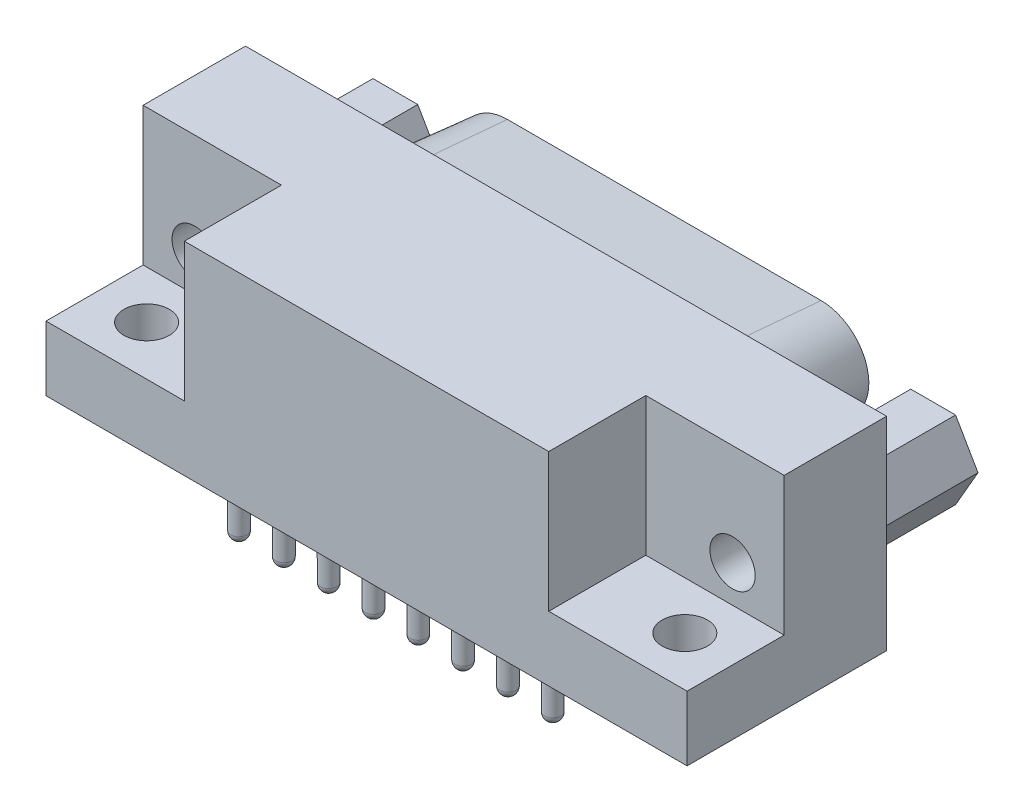
from build123d import *

# Parameters (mm, degrees)
SKETCH1_W                    = 39.62
SKETCH1_H                    = 12.33
BASE_EXTRUDE_DEPTH           = 12.55
SKETCH2_W                    = 8.55
SKETCH2_H                    = 6
CUT_EXTRUDE1_DEPTH           = 8.55
SKETCH3_R                    = 1.4
CUT_EXTRUDE2_DEPTH           = 33.442375067
BOSS_EXTRUDE1_DEPTH          = 6.07
SKETCH5_R                    = 1.4
CUT_EXTRUDE3_DEPTH           = 6.07
BOSS_EXTRUDE2_DEPTH          = 6.07
BOSS_EXTRUDE2_TAPER          = 5
SKETCH13_R                   = 1.4
CUT_EXTRUDE7_DEPTH           = 5
SKETCH7_R                    = 0.5
CUT_EXTRUDE4_DEPTH           = 9.47
CHAMFER1_SIZE                = 0.55
LPATTERN1_COUNT              = 8
LPATTERN1_PITCH              = 2.75
CHAMFER1_OF_LPATTERN1_SIZE   = 0.55
CUT_EXTRUDE5_START           = -9.47
SKETCH8_R                    = 0.5
CUT_EXTRUDE5_DEPTH           = 9.47
CHAMFER2_SIZE                = 0.55
LPATTERN2_COUNT              = 7
LPATTERN2_PITCH              = 2.75
CHAMFER2_OF_LPATTERN2_SIZE   = 0.55
SKETCH9_R                    = 0.5
BOSS_EXTRUDE3_DEPTH          = 3
DOME1_FACE_RADIUS            = 0.5
DOME1_HEIGHT                 = 0.5
LPATTERN3_COUNT              = 8
LPATTERN3_PITCH              = 2.77
LPATTERN3_COPY_1_FACE_RADIUS = 0.5
LPATTERN3_COPY_1_HEIGHT      = 0.5
LPATTERN3_COPY_2_FACE_RADIUS = 0.5
LPATTERN3_COPY_2_HEIGHT      = 0.5
LPATTERN3_COPY_3_FACE_RADIUS = 0.5
LPATTERN3_COPY_3_HEIGHT      = 0.5
LPATTERN3_COPY_4_FACE_RADIUS = 0.5
LPATTERN3_COPY_4_HEIGHT      = 0.5
LPATTERN3_COPY_5_FACE_RADIUS = 0.5
LPATTERN3_COPY_5_HEIGHT      = 0.5
LPATTERN3_COPY_6_FACE_RADIUS = 0.5
LPATTERN3_COPY_6_HEIGHT      = 0.5
LPATTERN3_COPY_7_FACE_RADIUS = 0.5
LPATTERN3_COPY_7_HEIGHT      = 0.5
SKETCH10_R                   = 0.5
BOSS_EXTRUDE4_DEPTH          = 3
DOME2_FACE_RADIUS            = 0.5
DOME2_HEIGHT                 = 0.5
LPATTERN4_COUNT              = 7
LPATTERN4_PITCH              = 2.77
LPATTERN4_COPY_1_FACE_RADIUS = 0.5
LPATTERN4_COPY_1_HEIGHT      = 0.5
LPATTERN4_COPY_2_FACE_RADIUS = 0.5
LPATTERN4_COPY_2_HEIGHT      = 0.5
LPATTERN4_COPY_3_FACE_RADIUS = 0.5
LPATTERN4_COPY_3_HEIGHT      = 0.5
LPATTERN4_COPY_4_FACE_RADIUS = 0.5
LPATTERN4_COPY_4_HEIGHT      = 0.5
LPATTERN4_COPY_5_FACE_RADIUS = 0.5
LPATTERN4_COPY_5_HEIGHT      = 0.5
LPATTERN4_COPY_6_FACE_RADIUS = 0.5
LPATTERN4_COPY_6_HEIGHT      = 0.5
CUT_EXTRUDE6_DEPTH           = 0.001


with BuildPart() as part:
    # Sketch1 → Base-Extrude (new body)
    with BuildSketch(Plane(origin=(0, 0, 0), x_dir=(1, 0, 0), z_dir=(0, 1, 0))):
        with Locations((9.65, 4.395)):
            Rectangle(SKETCH1_W, SKETCH1_H)
    extrude(amount=BASE_EXTRUDE_DEPTH)

    # Sketch2 → Cut-Extrude1 (cut)
    with BuildSketch(Plane(origin=(0, 12.55, 0), x_dir=(-1, 0, 0), z_dir=(0, 1, 0))):
        with Locations((5.885, -1.23)):
            Rectangle(SKETCH2_W, SKETCH2_H)
    cut_extrude1 = extrude(amount=-CUT_EXTRUDE1_DEPTH, mode=Mode.SUBTRACT)

    # Sketch3 → Cut-Extrude2 (cut, through all)
    with BuildSketch(Plane(origin=(0, 4, 0), x_dir=(-1, 0, 0), z_dir=(0, 1, 0))):
        with Locations(Location((6.98, -1.27, 0), (0, 0, 90))):
            Circle(SKETCH3_R)
    cut_extrude2 = extrude(amount=-CUT_EXTRUDE2_DEPTH, mode=Mode.SUBTRACT)

    # Sketch4 → Boss-Extrude1 (add)
    with BuildSketch(Plane(origin=(0, 0, -10.56), x_dir=(-1, 0, 0), z_dir=(0, 0, -1))):
        Polygon((8.355, 3.881109632), (5.585, 3.881109632), (4.2, 6.28), (5.585, 8.678890368), (8.355, 8.678890368), (9.74, 6.28), align=None)
    boss_extrude1 = extrude(amount=BOSS_EXTRUDE1_DEPTH)

    # Sketch5 → Cut-Extrude3 (cut)
    with BuildSketch(Plane(origin=(0, 0, -16.63), x_dir=(-1, 0, 0), z_dir=(0, 0, -1))):
        with Locations((6.97, 6.28)):
            Circle(SKETCH5_R)
    cut_extrude3 = extrude(amount=-CUT_EXTRUDE3_DEPTH, mode=Mode.SUBTRACT)

    # Sketch6 → Boss-Extrude2 (add)
    with BuildSketch(Plane(origin=(0, 0, -10.56), x_dir=(-1, 0, 0), z_dir=(0, 0, -1))):
        with BuildLine():
            ThreePointArc((-19.345, 11.18), (-22.388072176, 9.388227393), (-22.297527475, 5.857995247))
            Line((-22.297527475, 5.857995247), (-20.912527475, 3.637995247))
            ThreePointArc((-20.912527475, 3.637995247), (-19.648227393, 2.436927824), (-17.96, 2))
            Line((-17.96, 2), (-1.34, 2))
            ThreePointArc((-1.34, 2), (0.348227393, 2.436927824), (1.612527475, 3.637995247))
            Line((1.612527475, 3.637995247), (2.997527475, 5.857995247))
            ThreePointArc((2.997527475, 5.857995247), (3.088072176, 9.388227393), (0.045, 11.18))
            Line((0.045, 11.18), (-19.345, 11.18))
        make_face()
    extrude(amount=BOSS_EXTRUDE2_DEPTH, taper=BOSS_EXTRUDE2_TAPER)

    # Sketch13 → Cut-Extrude7 (cut)
    with BuildSketch(Plane.XY.offset(-4.23)):
        with Locations(Location((-6.97, 6.28, 0), (0, 0, 180))):
            Circle(SKETCH13_R)
    cut_extrude7 = extrude(amount=-CUT_EXTRUDE7_DEPTH, mode=Mode.SUBTRACT)

    # Mirror1: Cut-Extrude1, Cut-Extrude2, Boss-Extrude1, Cut-Extrude3, Cut-Extrude7 across plane
    add(cut_extrude1.mirror(Plane.ZY.offset(-9.65)), mode=Mode.SUBTRACT)
    add(cut_extrude2.mirror(Plane.ZY.offset(-9.65)), mode=Mode.SUBTRACT)
    add(boss_extrude1.mirror(Plane.ZY.offset(-9.65)))
    add(cut_extrude3.mirror(Plane.ZY.offset(-9.65)), mode=Mode.SUBTRACT)
    add(cut_extrude7.mirror(Plane.ZY.offset(-9.65)), mode=Mode.SUBTRACT)

    # Sketch7 → Cut-Extrude4 (cut)
    with BuildSketch(Plane(origin=(0, 0, -16.63), x_dir=(-1, 0, 0), z_dir=(0, 0, -1))):
        with Locations((-0.45, 7.69)):
            Circle(SKETCH7_R)
    cut_extrude4 = extrude(amount=-CUT_EXTRUDE4_DEPTH, mode=Mode.SUBTRACT)

    # Chamfer1
    chamfer1_edges = [part.edges().sort_by_distance(p)[0] for p in [
        (0.95, 7.69, -16.63),
    ]]
    chamfer(chamfer1_edges, length=CHAMFER1_SIZE)

    # LPattern1: Cut-Extrude4 ×8
    with Locations(*[(i * LPATTERN1_PITCH, 0, 0) for i in range(1, LPATTERN1_COUNT)]):
        add(cut_extrude4, mode=Mode.SUBTRACT)

    # Chamfer1 of LPattern1
    chamfer1_of_lpattern1_edges = [part.edges().sort_by_distance(p)[0] for p in [
        (3.7, 7.69, -16.63),
        (6.45, 7.69, -16.63),
        (9.2, 7.69, -16.63),
        (11.95, 7.69, -16.63),
        (14.7, 7.69, -16.63),
        (17.45, 7.69, -16.63),
        (20.2, 7.69, -16.63),
    ]]
    chamfer(chamfer1_of_lpattern1_edges, length=CHAMFER1_OF_LPATTERN1_SIZE)

    # Sketch8 → Cut-Extrude5 (cut)
    with BuildSketch(Plane(origin=(0, 0, -16.63), x_dir=(-1, 0, 0), z_dir=(0, 0, -1)).offset(CUT_EXTRUDE5_START)):
        with Locations((-1.825, 4.85)):
            Circle(SKETCH8_R)
    cut_extrude5 = extrude(amount=CUT_EXTRUDE5_DEPTH, mode=Mode.SUBTRACT)

    # Chamfer2
    chamfer2_edges = [part.edges().sort_by_distance(p)[0] for p in [
        (2.325, 4.85, -16.63),
    ]]
    chamfer(chamfer2_edges, length=CHAMFER2_SIZE)

    # LPattern2: Cut-Extrude5 ×7
    with Locations(*[(i * LPATTERN2_PITCH, 0, 0) for i in range(1, LPATTERN2_COUNT)]):
        add(cut_extrude5, mode=Mode.SUBTRACT)

    # Chamfer2 of LPattern2
    chamfer2_of_lpattern2_edges = [part.edges().sort_by_distance(p)[0] for p in [
        (5.075, 4.85, -16.63),
        (7.825, 4.85, -16.63),
        (10.575, 4.85, -16.63),
        (13.325, 4.85, -16.63),
        (16.075, 4.85, -16.63),
        (18.825, 4.85, -16.63),
    ]]
    chamfer(chamfer2_of_lpattern2_edges, length=CHAMFER2_OF_LPATTERN2_SIZE)

    # Sketch9 → Boss-Extrude3 (add)
    with BuildSketch(Plane.XZ):
        with Locations(Location((0, 0, 0), (0, 0, 90))):
            Circle(SKETCH9_R)
    boss_extrude3 = extrude(amount=BOSS_EXTRUDE3_DEPTH)

    # Dome1: a dome of height H over a round flat face of radius A is a cap of a sphere of radius (A * A + H * H) / (2 * H)
    dome1_r = (DOME1_FACE_RADIUS * DOME1_FACE_RADIUS + DOME1_HEIGHT * DOME1_HEIGHT) / (2 * DOME1_HEIGHT)
    dome1_base = Plane((0, -3, 0), z_dir=(0, -1, 0))
    with Locations(dome1_base.offset(DOME1_HEIGHT - dome1_r)):
        dome1_ball = Sphere(dome1_r, mode=Mode.PRIVATE)
    add(split(dome1_ball, bisect_by=dome1_base, keep=Keep.TOP, mode=Mode.PRIVATE))

    # LPattern3: Boss-Extrude3 ×8
    with Locations(*[(i * LPATTERN3_PITCH, 0, 0) for i in range(1, LPATTERN3_COUNT)]):
        add(boss_extrude3)

    # LPattern3 copy 1: a dome of height H over a round flat face of radius A is a cap of a sphere of radius (A * A + H * H) / (2 * H)
    lpattern3_copy_1_r = (LPATTERN3_COPY_1_FACE_RADIUS * LPATTERN3_COPY_1_FACE_RADIUS + LPATTERN3_COPY_1_HEIGHT * LPATTERN3_COPY_1_HEIGHT) / (2 * LPATTERN3_COPY_1_HEIGHT)
    lpattern3_copy_1_base = Plane((2.77, -3, 0), z_dir=(0, -1, 0))
    with Locations(lpattern3_copy_1_base.offset(LPATTERN3_COPY_1_HEIGHT - lpattern3_copy_1_r)):
        lpattern3_copy_1_ball = Sphere(lpattern3_copy_1_r, mode=Mode.PRIVATE)
    add(split(lpattern3_copy_1_ball, bisect_by=lpattern3_copy_1_base, keep=Keep.TOP, mode=Mode.PRIVATE))

    # LPattern3 copy 2: a dome of height H over a round flat face of radius A is a cap of a sphere of radius (A * A + H * H) / (2 * H)
    lpattern3_copy_2_r = (LPATTERN3_COPY_2_FACE_RADIUS * LPATTERN3_COPY_2_FACE_RADIUS + LPATTERN3_COPY_2_HEIGHT * LPATTERN3_COPY_2_HEIGHT) / (2 * LPATTERN3_COPY_2_HEIGHT)
    lpattern3_copy_2_base = Plane((5.54, -3, 0), z_dir=(0, -1, 0))
    with Locations(lpattern3_copy_2_base.offset(LPATTERN3_COPY_2_HEIGHT - lpattern3_copy_2_r)):
        lpattern3_copy_2_ball = Sphere(lpattern3_copy_2_r, mode=Mode.PRIVATE)
    add(split(lpattern3_copy_2_ball, bisect_by=lpattern3_copy_2_base, keep=Keep.TOP, mode=Mode.PRIVATE))

    # LPattern3 copy 3: a dome of height H over a round flat face of radius A is a cap of a sphere of radius (A * A + H * H) / (2 * H)
    lpattern3_copy_3_r = (LPATTERN3_COPY_3_FACE_RADIUS * LPATTERN3_COPY_3_FACE_RADIUS + LPATTERN3_COPY_3_HEIGHT * LPATTERN3_COPY_3_HEIGHT) / (2 * LPATTERN3_COPY_3_HEIGHT)
    lpattern3_copy_3_base = Plane((8.31, -3, 0), z_dir=(0, -1, 0))
    with Locations(lpattern3_copy_3_base.offset(LPATTERN3_COPY_3_HEIGHT - lpattern3_copy_3_r)):
        lpattern3_copy_3_ball = Sphere(lpattern3_copy_3_r, mode=Mode.PRIVATE)
    add(split(lpattern3_copy_3_ball, bisect_by=lpattern3_copy_3_base, keep=Keep.TOP, mode=Mode.PRIVATE))

    # LPattern3 copy 4: a dome of height H over a round flat face of radius A is a cap of a sphere of radius (A * A + H * H) / (2 * H)
    lpattern3_copy_4_r = (LPATTERN3_COPY_4_FACE_RADIUS * LPATTERN3_COPY_4_FACE_RADIUS + LPATTERN3_COPY_4_HEIGHT * LPATTERN3_COPY_4_HEIGHT) / (2 * LPATTERN3_COPY_4_HEIGHT)
    lpattern3_copy_4_base = Plane((11.08, -3, 0), z_dir=(0, -1, 0))
    with Locations(lpattern3_copy_4_base.offset(LPATTERN3_COPY_4_HEIGHT - lpattern3_copy_4_r)):
        lpattern3_copy_4_ball = Sphere(lpattern3_copy_4_r, mode=Mode.PRIVATE)
    add(split(lpattern3_copy_4_ball, bisect_by=lpattern3_copy_4_base, keep=Keep.TOP, mode=Mode.PRIVATE))

    # LPattern3 copy 5: a dome of height H over a round flat face of radius A is a cap of a sphere of radius (A * A + H * H) / (2 * H)
    lpattern3_copy_5_r = (LPATTERN3_COPY_5_FACE_RADIUS * LPATTERN3_COPY_5_FACE_RADIUS + LPATTERN3_COPY_5_HEIGHT * LPATTERN3_COPY_5_HEIGHT) / (2 * LPATTERN3_COPY_5_HEIGHT)
    lpattern3_copy_5_base = Plane((13.85, -3, 0), z_dir=(0, -1, 0))
    with Locations(lpattern3_copy_5_base.offset(LPATTERN3_COPY_5_HEIGHT - lpattern3_copy_5_r)):
        lpattern3_copy_5_ball = Sphere(lpattern3_copy_5_r, mode=Mode.PRIVATE)
    add(split(lpattern3_copy_5_ball, bisect_by=lpattern3_copy_5_base, keep=Keep.TOP, mode=Mode.PRIVATE))

    # LPattern3 copy 6: a dome of height H over a round flat face of radius A is a cap of a sphere of radius (A * A + H * H) / (2 * H)
    lpattern3_copy_6_r = (LPATTERN3_COPY_6_FACE_RADIUS * LPATTERN3_COPY_6_FACE_RADIUS + LPATTERN3_COPY_6_HEIGHT * LPATTERN3_COPY_6_HEIGHT) / (2 * LPATTERN3_COPY_6_HEIGHT)
    lpattern3_copy_6_base = Plane((16.62, -3, 0), z_dir=(0, -1, 0))
    with Locations(lpattern3_copy_6_base.offset(LPATTERN3_COPY_6_HEIGHT - lpattern3_copy_6_r)):
        lpattern3_copy_6_ball = Sphere(lpattern3_copy_6_r, mode=Mode.PRIVATE)
    add(split(lpattern3_copy_6_ball, bisect_by=lpattern3_copy_6_base, keep=Keep.TOP, mode=Mode.PRIVATE))

    # LPattern3 copy 7: a dome of height H over a round flat face of radius A is a cap of a sphere of radius (A * A + H * H) / (2 * H)
    lpattern3_copy_7_r = (LPATTERN3_COPY_7_FACE_RADIUS * LPATTERN3_COPY_7_FACE_RADIUS + LPATTERN3_COPY_7_HEIGHT * LPATTERN3_COPY_7_HEIGHT) / (2 * LPATTERN3_COPY_7_HEIGHT)
    lpattern3_copy_7_base = Plane((19.39, -3, 0), z_dir=(0, -1, 0))
    with Locations(lpattern3_copy_7_base.offset(LPATTERN3_COPY_7_HEIGHT - lpattern3_copy_7_r)):
        lpattern3_copy_7_ball = Sphere(lpattern3_copy_7_r, mode=Mode.PRIVATE)
    add(split(lpattern3_copy_7_ball, bisect_by=lpattern3_copy_7_base, keep=Keep.TOP, mode=Mode.PRIVATE))

    # Sketch10 → Boss-Extrude4 (add)
    with BuildSketch(Plane.XZ):
        with Locations(Location((1.385, -2.84, 0), (0, 0, 90))):
            Circle(SKETCH10_R)
    boss_extrude4 = extrude(amount=BOSS_EXTRUDE4_DEPTH)

    # Dome2: a dome of height H over a round flat face of radius A is a cap of a sphere of radius (A * A + H * H) / (2 * H)
    dome2_r = (DOME2_FACE_RADIUS * DOME2_FACE_RADIUS + DOME2_HEIGHT * DOME2_HEIGHT) / (2 * DOME2_HEIGHT)
    dome2_base = Plane((1.385, -3, -2.84), z_dir=(0, -1, 0))
    with Locations(dome2_base.offset(DOME2_HEIGHT - dome2_r)):
        dome2_ball = Sphere(dome2_r, mode=Mode.PRIVATE)
    add(split(dome2_ball, bisect_by=dome2_base, keep=Keep.TOP, mode=Mode.PRIVATE))

    # LPattern4: Boss-Extrude4 ×7
    with Locations(*[(i * LPATTERN4_PITCH, 0, 0) for i in range(1, LPATTERN4_COUNT)]):
        add(boss_extrude4)

    # LPattern4 copy 1: a dome of height H over a round flat face of radius A is a cap of a sphere of radius (A * A + H * H) / (2 * H)
    lpattern4_copy_1_r = (LPATTERN4_COPY_1_FACE_RADIUS * LPATTERN4_COPY_1_FACE_RADIUS + LPATTERN4_COPY_1_HEIGHT * LPATTERN4_COPY_1_HEIGHT) / (2 * LPATTERN4_COPY_1_HEIGHT)
    lpattern4_copy_1_base = Plane((4.155, -3, -2.84), z_dir=(0, -1, 0))
    with Locations(lpattern4_copy_1_base.offset(LPATTERN4_COPY_1_HEIGHT - lpattern4_copy_1_r)):
        lpattern4_copy_1_ball = Sphere(lpattern4_copy_1_r, mode=Mode.PRIVATE)
    add(split(lpattern4_copy_1_ball, bisect_by=lpattern4_copy_1_base, keep=Keep.TOP, mode=Mode.PRIVATE))

    # LPattern4 copy 2: a dome of height H over a round flat face of radius A is a cap of a sphere of radius (A * A + H * H) / (2 * H)
    lpattern4_copy_2_r = (LPATTERN4_COPY_2_FACE_RADIUS * LPATTERN4_COPY_2_FACE_RADIUS + LPATTERN4_COPY_2_HEIGHT * LPATTERN4_COPY_2_HEIGHT) / (2 * LPATTERN4_COPY_2_HEIGHT)
    lpattern4_copy_2_base = Plane((6.925, -3, -2.84), z_dir=(0, -1, 0))
    with Locations(lpattern4_copy_2_base.offset(LPATTERN4_COPY_2_HEIGHT - lpattern4_copy_2_r)):
        lpattern4_copy_2_ball = Sphere(lpattern4_copy_2_r, mode=Mode.PRIVATE)
    add(split(lpattern4_copy_2_ball, bisect_by=lpattern4_copy_2_base, keep=Keep.TOP, mode=Mode.PRIVATE))

    # LPattern4 copy 3: a dome of height H over a round flat face of radius A is a cap of a sphere of radius (A * A + H * H) / (2 * H)
    lpattern4_copy_3_r = (LPATTERN4_COPY_3_FACE_RADIUS * LPATTERN4_COPY_3_FACE_RADIUS + LPATTERN4_COPY_3_HEIGHT * LPATTERN4_COPY_3_HEIGHT) / (2 * LPATTERN4_COPY_3_HEIGHT)
    lpattern4_copy_3_base = Plane((9.695, -3, -2.84), z_dir=(0, -1, 0))
    with Locations(lpattern4_copy_3_base.offset(LPATTERN4_COPY_3_HEIGHT - lpattern4_copy_3_r)):
        lpattern4_copy_3_ball = Sphere(lpattern4_copy_3_r, mode=Mode.PRIVATE)
    add(split(lpattern4_copy_3_ball, bisect_by=lpattern4_copy_3_base, keep=Keep.TOP, mode=Mode.PRIVATE))

    # LPattern4 copy 4: a dome of height H over a round flat face of radius A is a cap of a sphere of radius (A * A + H * H) / (2 * H)
    lpattern4_copy_4_r = (LPATTERN4_COPY_4_FACE_RADIUS * LPATTERN4_COPY_4_FACE_RADIUS + LPATTERN4_COPY_4_HEIGHT * LPATTERN4_COPY_4_HEIGHT) / (2 * LPATTERN4_COPY_4_HEIGHT)
    lpattern4_copy_4_base = Plane((12.465, -3, -2.84), z_dir=(0, -1, 0))
    with Locations(lpattern4_copy_4_base.offset(LPATTERN4_COPY_4_HEIGHT - lpattern4_copy_4_r)):
        lpattern4_copy_4_ball = Sphere(lpattern4_copy_4_r, mode=Mode.PRIVATE)
    add(split(lpattern4_copy_4_ball, bisect_by=lpattern4_copy_4_base, keep=Keep.TOP, mode=Mode.PRIVATE))

    # LPattern4 copy 5: a dome of height H over a round flat face of radius A is a cap of a sphere of radius (A * A + H * H) / (2 * H)
    lpattern4_copy_5_r = (LPATTERN4_COPY_5_FACE_RADIUS * LPATTERN4_COPY_5_FACE_RADIUS + LPATTERN4_COPY_5_HEIGHT * LPATTERN4_COPY_5_HEIGHT) / (2 * LPATTERN4_COPY_5_HEIGHT)
    lpattern4_copy_5_base = Plane((15.235, -3, -2.84), z_dir=(0, -1, 0))
    with Locations(lpattern4_copy_5_base.offset(LPATTERN4_COPY_5_HEIGHT - lpattern4_copy_5_r)):
        lpattern4_copy_5_ball = Sphere(lpattern4_copy_5_r, mode=Mode.PRIVATE)
    add(split(lpattern4_copy_5_ball, bisect_by=lpattern4_copy_5_base, keep=Keep.TOP, mode=Mode.PRIVATE))

    # LPattern4 copy 6: a dome of height H over a round flat face of radius A is a cap of a sphere of radius (A * A + H * H) / (2 * H)
    lpattern4_copy_6_r = (LPATTERN4_COPY_6_FACE_RADIUS * LPATTERN4_COPY_6_FACE_RADIUS + LPATTERN4_COPY_6_HEIGHT * LPATTERN4_COPY_6_HEIGHT) / (2 * LPATTERN4_COPY_6_HEIGHT)
    lpattern4_copy_6_base = Plane((18.005, -3, -2.84), z_dir=(0, -1, 0))
    with Locations(lpattern4_copy_6_base.offset(LPATTERN4_COPY_6_HEIGHT - lpattern4_copy_6_r)):
        lpattern4_copy_6_ball = Sphere(lpattern4_copy_6_r, mode=Mode.PRIVATE)
    add(split(lpattern4_copy_6_ball, bisect_by=lpattern4_copy_6_base, keep=Keep.TOP, mode=Mode.PRIVATE))

    # Sketch11 → Cut-Extrude6 (cut)
    with BuildSketch(Plane(origin=(0, 0, -16.63), x_dir=(-1, 0, 0), z_dir=(0, 0, -1))):
        with BuildLine():
            Line((0.822593861, 4.13081419), (2.207593861, 6.35081419))
            ThreePointArc((2.207593861, 6.35081419), (2.273913792, 8.936550795), (0.045, 10.248943812))
            Line((0.045, 10.248943812), (-19.345, 10.248943812))
            ThreePointArc((-19.345, 10.248943812), (-21.573913792, 8.936550795), (-21.507593861, 6.35081419))
            Line((-21.507593861, 6.35081419), (-20.122593861, 4.13081419))
            ThreePointArc((-20.122593861, 4.13081419), (-19.196550795, 3.251086208), (-17.96, 2.931056188))
            Line((-17.96, 2.931056188), (-1.34, 2.931056188))
            ThreePointArc((-1.34, 2.931056188), (-0.103449205, 3.251086208), (0.822593861, 4.13081419))
        make_face()
    extrude(amount=-CUT_EXTRUDE6_DEPTH, mode=Mode.SUBTRACT)


solid = part.part
